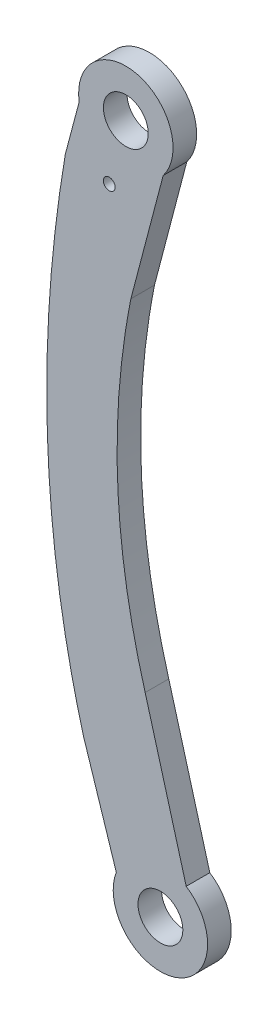
from build123d import *

# Parameters (mm, degrees)
SKETCH1_R           = 1
SKETCH1_W           = 7.92
SKETCH1_H           = 7.92
SKETCH1_R_2         = 3.8
BOSS_EXTRUDE1_DEPTH = 2
SKETCH2_R           = 8
SKETCH2_W           = 7.92
SKETCH2_H           = 7.92
BOSS_EXTRUDE2_DEPTH = 2


with BuildPart() as part:
    # Sketch1 → Boss-Extrude1 (new body, symmetric)
    with BuildSketch(Plane.XY):
        with BuildLine():
            Line((-5.004193268, -11.768083729), (1.264827755, 12.086469882))
            ThreePointArc((1.264827755, 12.086469882), (-3.646245645, 20.982534185), (-12.767631248, 16.503814873))
            Line((-12.767631248, 16.503814873), (-16.10900409, 3.908669428))
            add(Edge.make_bspline(
                [(-16.10900409, 3.908669428), (-19.377716834, -15.242508961), (-20.646085271, -43.801923377), (-15.357286602, -71.564124193), (-13.027019985, -79.992281382)],
                knots=[0, 0, 0, 0, 0.615830564, 0.891753854, 0.891753854, 0.891753854, 0.891753854], degree=3))
            Line((-13.027019985, -79.992281382), (-5.967709179, -101.821397306))
            ThreePointArc((-5.967709179, -101.821397306), (-2.543292548, -94.302394888), (5.340555406, -96.773622937))
            Line((5.340555406, -96.773622937), (-2.58265982, -68.335822015))
            add(Edge.make_bspline(
                [(-2.58265982, -68.335822015), (-10.677441901, -40.31981723), (-5.004193268, -11.768083729)],
                knots=[0, 0, 0, 1, 1, 1], degree=2))
        make_face()
        with Locations((-8.672039016, 3.248347704)):
            Circle(SKETCH1_R, mode=Mode.SUBTRACT)
        with Locations((-5.857463234, 13.958219751)):
            Rectangle(SKETCH1_W, SKETCH1_H, mode=Mode.SUBTRACT)
        with BuildLine():
            ThreePointArc((6.239474416, -100), (6.010544893, -98.325368373), (5.340555406, -96.773622937))
            ThreePointArc((5.340555406, -96.773622937), (-2.543292548, -94.302394888), (-5.967709179, -101.821397306))
            ThreePointArc((-5.967709179, -101.821397306), (0.92078017, -106.171159119), (6.239474416, -100))
        make_face()
        with Locations((0, -100)):
            Rectangle(SKETCH1_W, SKETCH1_H, mode=Mode.SUBTRACT)
        with Locations((0, -100)):
            Rectangle(SKETCH1_W, SKETCH1_H)
        with Locations((0, -100)):
            Circle(SKETCH1_R_2, mode=Mode.SUBTRACT)
        with Locations((-5.857463234, 13.958219751)):
            Rectangle(SKETCH1_W, SKETCH1_H)
        with Locations((-5.857463234, 13.958219751)):
            Circle(SKETCH1_R_2, mode=Mode.SUBTRACT)
    extrude(amount=BOSS_EXTRUDE1_DEPTH, both=True)

    # Sketch2 → Boss-Extrude2 (add, symmetric)
    with BuildSketch(Plane.XY):
        with Locations((0, -100)):
            Circle(SKETCH2_R)
        with Locations((0, -100)):
            Rectangle(SKETCH2_W, SKETCH2_H, mode=Mode.SUBTRACT)
        with Locations((-5.857463234, 13.958219751)):
            Circle(SKETCH2_R)
        with Locations((-5.857463234, 13.958219751)):
            Rectangle(SKETCH2_W, SKETCH2_H, mode=Mode.SUBTRACT)
    extrude(amount=BOSS_EXTRUDE2_DEPTH, both=True)


solid = part.part
